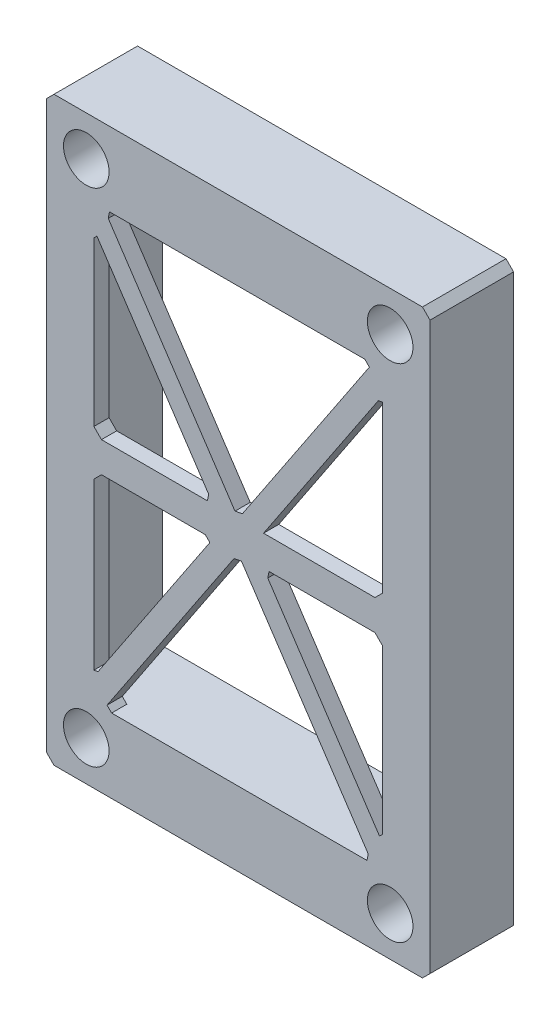
from build123d import *
from OCP.BRepFilletAPI import BRepFilletAPI_MakeChamfer

# Parameters (mm, degrees)
SKETCH2_W           = 25.25
SKETCH2_H           = 38.25
SKETCH2_R           = 1.5
SKETCH2_W_2         = 19
SKETCH2_H_2         = 28.5
SKETCH2_R_2         = 1
BOSS_EXTRUDE1_DEPTH = 3
CHAMFER1_SIZE       = 0.5
CHAMFER1_SIZE2      = 0.360555128
CHAMFER1_SIZE2_2    = 0.382352941
CUT_EXTRUDE1_DEPTH  = 2
SKETCH5_R           = 1.5
SKETCH5_W           = 21
SKETCH5_H           = 28.5
BOSS_EXTRUDE2_DEPTH = 2.5


with BuildPart() as part:
    # Sketch2 → Boss-Extrude1 (new body)
    with BuildSketch(Plane.XY):
        Rectangle(SKETCH2_W, SKETCH2_H)
        with Locations((-10, -16.5)):
            Circle(SKETCH2_R, mode=Mode.SUBTRACT)
        with Locations((10, -16.5)):
            Circle(SKETCH2_R, mode=Mode.SUBTRACT)
        with Locations((10, 16.5)):
            Circle(SKETCH2_R, mode=Mode.SUBTRACT)
        with Locations((-10, 16.5)):
            Circle(SKETCH2_R, mode=Mode.SUBTRACT)
        Rectangle(SKETCH2_W_2, SKETCH2_H_2, mode=Mode.SUBTRACT)
        Polygon((-1.666666667, -1), (-1, 0), (-1.666666667, 1), (-9.5, 1), (-9.5, -1), align=None)
        with BuildLine():
            Line((-9.5, -14.25), (-8.833333333, -14.25))
            Line((-8.833333333, -14.25), (0, -1))
            ThreePointArc((0, -1), (-0.707106781, -0.707106781), (-1, 0))
            Line((-1, 0), (-1.666666667, -1))
            Line((-1.666666667, -1), (-9.5, -12.75))
            Line((-9.5, -12.75), (-9.5, -14.25))
        make_face()
        with BuildLine():
            Line((8.833333333, -14.25), (9.5, -14.25))
            Line((9.5, -14.25), (9.5, -12.75))
            Line((9.5, -12.75), (1.666666667, -1))
            Line((1.666666667, -1), (1, 0))
            ThreePointArc((1, 0), (0.707106781, -0.707106781), (0, -1))
            Line((0, -1), (8.833333333, -14.25))
        make_face()
        Polygon((1.666666667, -1), (9.5, -1), (9.5, 1), (1.666666667, 1), (1, 0), align=None)
        with BuildLine():
            ThreePointArc((0, 1), (0.707106781, 0.707106781), (1, 0))
            Line((1, 0), (1.666666667, 1))
            Line((1.666666667, 1), (9.5, 12.75))
            Line((9.5, 12.75), (9.5, 14.25))
            Line((9.5, 14.25), (8.833333333, 14.25))
            Line((8.833333333, 14.25), (0, 1))
        make_face()
        Circle(SKETCH2_R_2)
        with BuildLine():
            Line((-1.666666667, 1), (-1, 0))
            ThreePointArc((-1, 0), (-0.707106781, 0.707106781), (0, 1))
            Line((0, 1), (-8.833333333, 14.25))
            Line((-8.833333333, 14.25), (-9.5, 14.25))
            Line((-9.5, 14.25), (-9.5, 12.75))
            Line((-9.5, 12.75), (-1.666666667, 1))
        make_face()
    extrude(amount=BOSS_EXTRUDE1_DEPTH)

    # Chamfer1: one chamfer whose edges measure the first distance from different faces: ONE call of the kernel's chamfer builder (chamfer() names one face for all edges)
    chamfer1_edges_1 = [part.edges().sort_by_distance(p)[0] for p in [
        (-12.625, 19.125, 1.5),
        (12.625, 19.125, 1.5),
        (12.625, -19.125, 1.5),
        (-12.625, -19.125, 1.5),
        (-9.5, 1, 1.5),
        (-9.5, -1, 1.5),
        (9.5, -1, 1.5),
        (9.5, 1, 1.5),
    ]]
    chamfer1_edges_2 = [part.edges().sort_by_distance(p)[0] for p in [
        (-1.666666667, 1, 1.5),
    ]]
    chamfer1_side_2 = [part.faces().sort_by_distance(p)[0] for p in [
        (-5.583333333, 6.875, 1.5),
    ]]
    chamfer1_edges_3 = [part.edges().sort_by_distance(p)[0] for p in [
        (-9.5, 12.75, 1.5),
    ]]
    chamfer1_side_3 = [part.faces().sort_by_distance(p)[0] for p in [
        (-9.5, 6.875, 1.5),
    ]]
    chamfer1_edges_4 = [part.edges().sort_by_distance(p)[0] for p in [
        (-1.666666667, -1, 1.5),
    ]]
    chamfer1_side_4 = [part.faces().sort_by_distance(p)[0] for p in [
        (-5.583333333, -1, 1.5),
    ]]
    chamfer1_edges_5 = [part.edges().sort_by_distance(p)[0] for p in [
        (-9.5, -12.75, 1.5),
    ]]
    chamfer1_side_5 = [part.faces().sort_by_distance(p)[0] for p in [
        (-5.583333333, -6.875, 1.5),
    ]]
    chamfer1_edges_6 = [part.edges().sort_by_distance(p)[0] for p in [
        (8.833333333, 14.25, 1.5),
    ]]
    chamfer1_side_6 = [part.faces().sort_by_distance(p)[0] for p in [
        (0, 14.25, 1.5),
    ]]
    chamfer1_edges_7 = [part.edges().sort_by_distance(p)[0] for p in [
        (-8.833333333, 14.25, 1.5),
    ]]
    chamfer1_side_7 = [part.faces().sort_by_distance(p)[0] for p in [
        (-4.416666667, 7.625, 1.5),
    ]]
    chamfer1_edges_8 = [part.edges().sort_by_distance(p)[0] for p in [
        (0, 1, 1.5),
    ]]
    chamfer1_side_8 = [part.faces().sort_by_distance(p)[0] for p in [
        (4.416666667, 7.625, 1.5),
    ]]
    chamfer1_edges_9 = [part.edges().sort_by_distance(p)[0] for p in [
        (9.5, -12.75, 1.5),
    ]]
    chamfer1_side_9 = [part.faces().sort_by_distance(p)[0] for p in [
        (9.5, -6.875, 1.5),
    ]]
    chamfer1_edges_10 = [part.edges().sort_by_distance(p)[0] for p in [
        (1.666666667, -1, 1.5),
    ]]
    chamfer1_side_10 = [part.faces().sort_by_distance(p)[0] for p in [
        (5.583333333, -6.875, 1.5),
    ]]
    chamfer1_edges_11 = [part.edges().sort_by_distance(p)[0] for p in [
        (-8.833333333, -14.25, 1.5),
    ]]
    chamfer1_side_11 = [part.faces().sort_by_distance(p)[0] for p in [
        (0, -14.25, 1.5),
    ]]
    chamfer1_edges_12 = [part.edges().sort_by_distance(p)[0] for p in [
        (8.833333333, -14.25, 1.5),
    ]]
    chamfer1_side_12 = [part.faces().sort_by_distance(p)[0] for p in [
        (4.416666667, -7.625, 1.5),
    ]]
    chamfer1_edges_13 = [part.edges().sort_by_distance(p)[0] for p in [
        (0, -1, 1.5),
    ]]
    chamfer1_side_13 = [part.faces().sort_by_distance(p)[0] for p in [
        (-4.416666667, -7.625, 1.5),
    ]]
    chamfer1_edges_14 = [part.edges().sort_by_distance(p)[0] for p in [
        (9.5, 12.75, 1.5),
    ]]
    chamfer1_side_14 = [part.faces().sort_by_distance(p)[0] for p in [
        (5.583333333, 6.875, 1.5),
    ]]
    chamfer1 = BRepFilletAPI_MakeChamfer(part.part.solid().wrapped)
    for e in chamfer1_edges_1:
        chamfer1.Add(CHAMFER1_SIZE, e.wrapped)
    for e in chamfer1_edges_2:
        chamfer1.Add(CHAMFER1_SIZE, CHAMFER1_SIZE2, e.wrapped, chamfer1_side_2[0].wrapped)  # the first distance lies on this face
    for e in chamfer1_edges_3:
        chamfer1.Add(CHAMFER1_SIZE, CHAMFER1_SIZE2, e.wrapped, chamfer1_side_3[0].wrapped)  # the first distance lies on this face
    for e in chamfer1_edges_4:
        chamfer1.Add(CHAMFER1_SIZE, CHAMFER1_SIZE2, e.wrapped, chamfer1_side_4[0].wrapped)  # the first distance lies on this face
    for e in chamfer1_edges_5:
        chamfer1.Add(CHAMFER1_SIZE, CHAMFER1_SIZE2, e.wrapped, chamfer1_side_5[0].wrapped)  # the first distance lies on this face
    for e in chamfer1_edges_6:
        chamfer1.Add(CHAMFER1_SIZE, CHAMFER1_SIZE2, e.wrapped, chamfer1_side_6[0].wrapped)  # the first distance lies on this face
    for e in chamfer1_edges_7:
        chamfer1.Add(CHAMFER1_SIZE, CHAMFER1_SIZE2, e.wrapped, chamfer1_side_7[0].wrapped)  # the first distance lies on this face
    for e in chamfer1_edges_8:
        chamfer1.Add(CHAMFER1_SIZE, CHAMFER1_SIZE2_2, e.wrapped, chamfer1_side_8[0].wrapped)  # the first distance lies on this face
    for e in chamfer1_edges_9:
        chamfer1.Add(CHAMFER1_SIZE, CHAMFER1_SIZE2, e.wrapped, chamfer1_side_9[0].wrapped)  # the first distance lies on this face
    for e in chamfer1_edges_10:
        chamfer1.Add(CHAMFER1_SIZE, CHAMFER1_SIZE2, e.wrapped, chamfer1_side_10[0].wrapped)  # the first distance lies on this face
    for e in chamfer1_edges_11:
        chamfer1.Add(CHAMFER1_SIZE, CHAMFER1_SIZE2, e.wrapped, chamfer1_side_11[0].wrapped)  # the first distance lies on this face
    for e in chamfer1_edges_12:
        chamfer1.Add(CHAMFER1_SIZE, CHAMFER1_SIZE2, e.wrapped, chamfer1_side_12[0].wrapped)  # the first distance lies on this face
    for e in chamfer1_edges_13:
        chamfer1.Add(CHAMFER1_SIZE, CHAMFER1_SIZE2_2, e.wrapped, chamfer1_side_13[0].wrapped)  # the first distance lies on this face
    for e in chamfer1_edges_14:
        chamfer1.Add(CHAMFER1_SIZE, CHAMFER1_SIZE2, e.wrapped, chamfer1_side_14[0].wrapped)  # the first distance lies on this face
    add(Compound.cast(chamfer1.Shape()), mode=Mode.REPLACE)

    # Sketch3 → Cut-Extrude1 (cut)
    with BuildSketch(Plane(origin=(0, 0, 0), x_dir=(-1, 0, 0), z_dir=(0, 0, -1))):
        Polygon((10.5, -14.25), (10.5, 14.25), (8.472778206, 14.25), (8.555983235, 13.833974853), (0.212091251, 1.318136877), (-0.277350098, 1.416025147), (-8.633333333, 13.95), (-8.333333333, 14.25), (-10.5, 14.25), (-10.5, -14.25), (-8.472778206, -14.25), (-8.555983235, -13.833974853), (-0.212091251, -1.318136877), (0.277350098, -1.416025147), (8.633333333, -13.95), (8.333333333, -14.25), align=None)
        Polygon((-1.666666667, 1), (-9, 1), (-9.5, 1.5), (-9.5, 12.389444872), (-9.222649902, 12.333974853), align=None, mode=Mode.SUBTRACT)
        Polygon((-9.5, -1.5), (-9, -1), (-2.027221794, -1), (-1.944016765, -1.416025147), (-9.3, -12.45), (-9.5, -12.25), align=None, mode=Mode.SUBTRACT)
        Polygon((9.5, 1.5), (9, 1), (2.027221794, 1), (1.944016765, 1.416025147), (9.3, 12.45), (9.5, 12.25), align=None, mode=Mode.SUBTRACT)
        Polygon((9.222649902, -12.333974853), (1.866666667, -1.3), (2.166666667, -1), (9, -1), (9.5, -1.5), (9.5, -12.389444872), align=None, mode=Mode.SUBTRACT)
    extrude(amount=-CUT_EXTRUDE1_DEPTH, mode=Mode.SUBTRACT)

    # Sketch5 → Boss-Extrude2 (add)
    with BuildSketch(Plane(origin=(0, 0, 0), x_dir=(-1, 0, 0), z_dir=(0, 0, -1))):
        Polygon((-12.125, -19.125), (12.125, -19.125), (12.625, -18.625), (12.625, 18.625), (12.125, 19.125), (-12.125, 19.125), (-12.625, 18.625), (-12.625, -18.625), align=None)
        with Locations((-10, -16.5)):
            Circle(SKETCH5_R, mode=Mode.SUBTRACT)
        with Locations((10, -16.5)):
            Circle(SKETCH5_R, mode=Mode.SUBTRACT)
        with Locations((10, 16.5)):
            Circle(SKETCH5_R, mode=Mode.SUBTRACT)
        with Locations((-10, 16.5)):
            Circle(SKETCH5_R, mode=Mode.SUBTRACT)
        Rectangle(SKETCH5_W, SKETCH5_H, mode=Mode.SUBTRACT)
    extrude(amount=BOSS_EXTRUDE2_DEPTH)


solid = part.part
